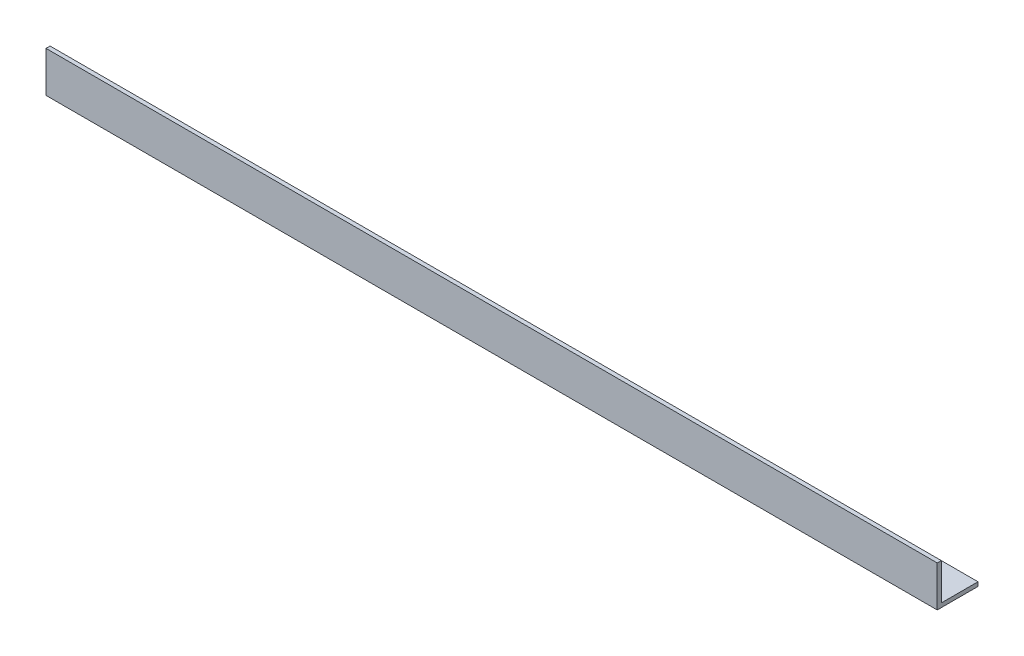
from build123d import *

# Parameters (mm, degrees)
EXTRUDE_1_DEPTH = 328


with BuildPart() as part:
    # Эскиз1 → Бобышка-Вытянуть1 (new body)
    with BuildSketch(Plane(origin=(0, 0, 0), x_dir=(0, 0, -1), z_dir=(1, 0, 0))):
        Polygon((0, 0), (0, 15), (1.5, 15), (1.5, 1.5), (15, 1.5), (15, 0), align=None)
    extrude(amount=EXTRUDE_1_DEPTH)


solid = part.part
